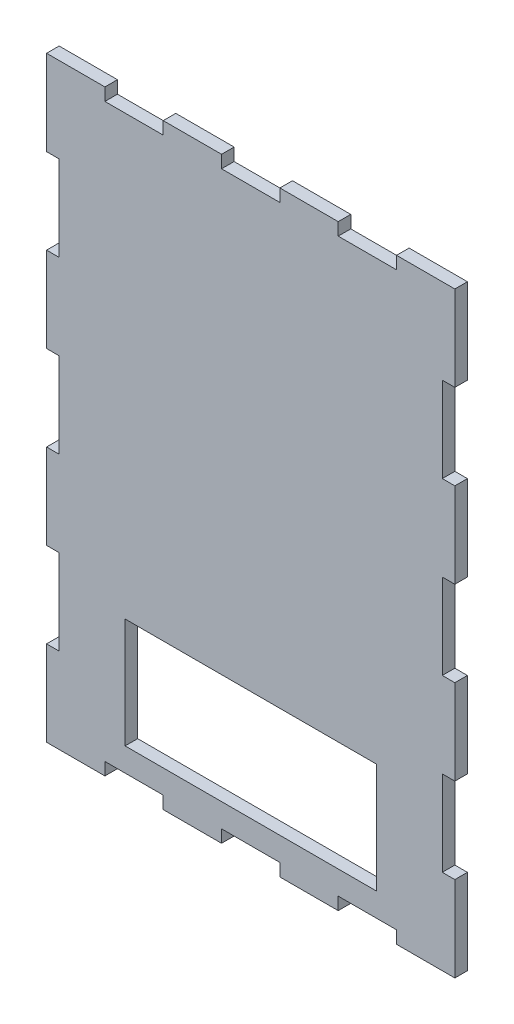
from build123d import *

# Parameters (mm, degrees)
BUITENAFMETING_RECHTHOEK_W  = 130
BUITENAFMETING_RECHTHOEK_H  = 190
PLAAT_DEPTH                 = 4
TAND_HOR_W                  = 18.571428572
TAND_HOR_H                  = 4
TAND_BOVEN_DEPTH            = 5
TANDEN_PATROON_BOVEN_COUNT  = 3
TANDEN_PATROON_BOVEN_PITCH  = 37.142857143
TAND_VER_W                  = 4
TAND_VER_H                  = 27.142857143
TAND_LINKS_DEPTH            = 5
TANDEN_PATROON_LINKS_COUNT  = 3
TANDEN_PATROON_LINKS_PITCH  = 54.285714286
TAND_O_W                    = 18.571428572
TAND_O_H                    = 4
TAND_ONDER_DEPTH            = 5
TANDEN_PATROON_ONDER_COUNT  = 3
TANDEN_PATROON_ONDER_PITCH  = 37.142857143
TAND_R_W                    = 4
TAND_R_H                    = 27.142857143
TAND_RECHTS_DEPTH           = 5
TANDEN_PATROON_RECHTS_COUNT = 3
TANDEN_PATROON_RECHTS_PITCH = 54.285714286
SKETCH1_W                   = 80
SKETCH1_H                   = 35
CUT_EXTRUDE1_DEPTH          = 10


with BuildPart() as part:
    # Buitenafmeting Rechthoek → Plaat (new body)
    with BuildSketch(Plane.XY):
        with Locations((65, 95)):
            Rectangle(BUITENAFMETING_RECHTHOEK_W, BUITENAFMETING_RECHTHOEK_H)
    extrude(amount=-PLAAT_DEPTH)

    # Tand Hor → Tand Boven (cut, through all)
    with BuildSketch(Plane.XY):
        with Locations((27.857142857, 188)):
            Rectangle(TAND_HOR_W, TAND_HOR_H)
    tand_boven = extrude(amount=-TAND_BOVEN_DEPTH, mode=Mode.SUBTRACT)

    # Tanden Patroon Boven: Tand Boven ×3
    with Locations(*[(i * TANDEN_PATROON_BOVEN_PITCH, 0, 0) for i in range(1, TANDEN_PATROON_BOVEN_COUNT)]):
        add(tand_boven, mode=Mode.SUBTRACT)

    # Tand Ver → Tand Links (cut, through all)
    with BuildSketch(Plane.XY):
        with Locations((2, 149.285714286)):
            Rectangle(TAND_VER_W, TAND_VER_H)
    tand_links = extrude(amount=-TAND_LINKS_DEPTH, mode=Mode.SUBTRACT)

    # Tanden Patroon Links: Tand Links ×3
    with Locations(*[(0, -i * TANDEN_PATROON_LINKS_PITCH, 0) for i in range(1, TANDEN_PATROON_LINKS_COUNT)]):
        add(tand_links, mode=Mode.SUBTRACT)

    # Tand O → Tand Onder (cut, through all)
    with BuildSketch(Plane.XY):
        with Locations((27.857142857, 2)):
            Rectangle(TAND_O_W, TAND_O_H)
    tand_onder = extrude(amount=-TAND_ONDER_DEPTH, mode=Mode.SUBTRACT)

    # Tanden Patroon Onder: Tand Onder ×3
    with Locations(*[(i * TANDEN_PATROON_ONDER_PITCH, 0, 0) for i in range(1, TANDEN_PATROON_ONDER_COUNT)]):
        add(tand_onder, mode=Mode.SUBTRACT)

    # Tand R → Tand Rechts (cut, through all)
    with BuildSketch(Plane.XY):
        with Locations((128, 149.285714286)):
            Rectangle(TAND_R_W, TAND_R_H)
    tand_rechts = extrude(amount=-TAND_RECHTS_DEPTH, mode=Mode.SUBTRACT)

    # Tanden Patroon Rechts: Tand Rechts ×3
    with Locations(*[(0, -i * TANDEN_PATROON_RECHTS_PITCH, 0) for i in range(1, TANDEN_PATROON_RECHTS_COUNT)]):
        add(tand_rechts, mode=Mode.SUBTRACT)

    # Sketch1 → Cut-Extrude1 (cut)
    with BuildSketch(Plane.XY):
        with Locations((65, 29)):
            Rectangle(SKETCH1_W, SKETCH1_H)
    extrude(amount=-CUT_EXTRUDE1_DEPTH, mode=Mode.SUBTRACT)


solid = part.part
